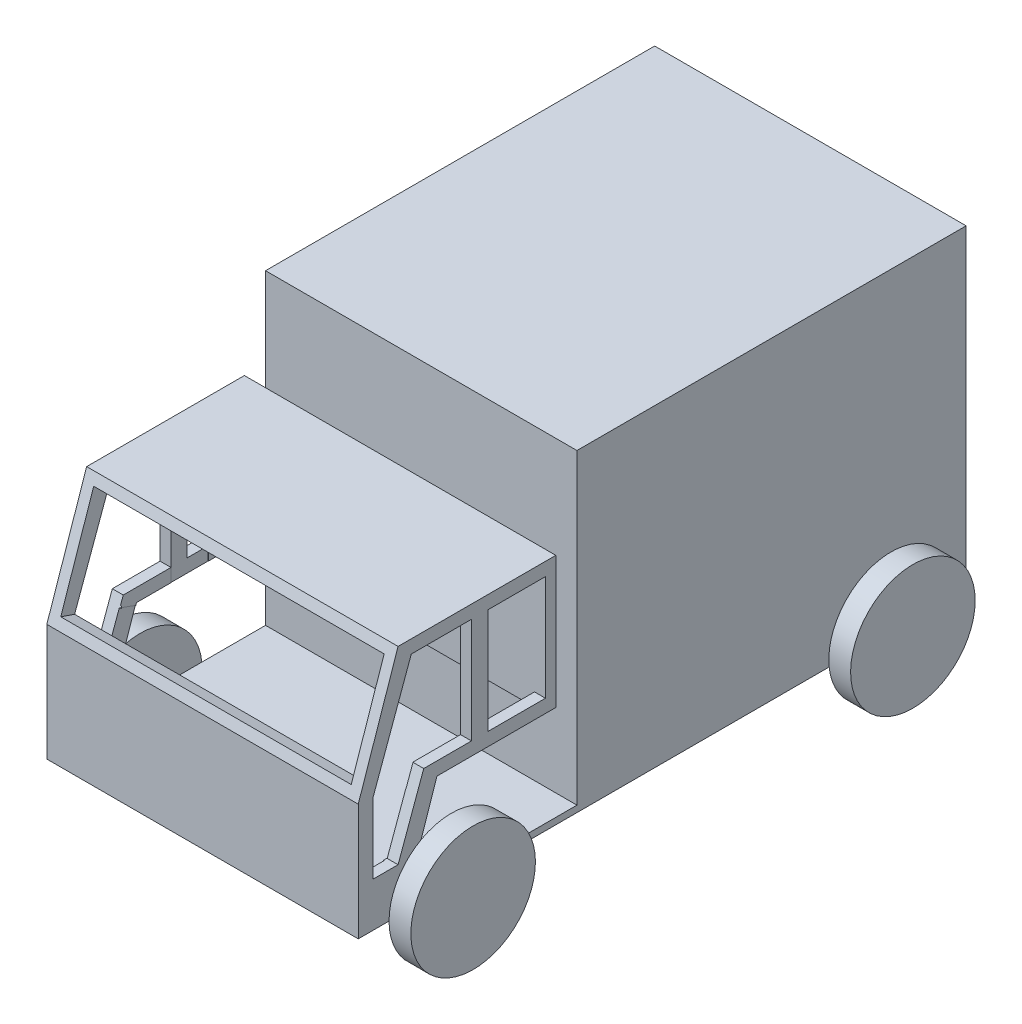
from build123d import *

# Parameters (mm, degrees)
IZIM2_W                     = 624.83438286
IZIM2_H                     = 493.118424104
Y_KSEKLIK_EKSTR_ZYON1_DEPTH = 500
IZIM4_R                     = 100
Y_KSEKLIK_EKSTR_ZYON2_DEPTH = 35
IZIM5_W                     = 975.967830922
IZIM5_H                     = 10.395315862
Y_KSEKLIK_EKSTR_ZYON3_DEPTH = 500
IZIM6_W                     = 317.202351564
IZIM6_H                     = 374.704466417
Y_KSEKLIK_EKSTR_ZYON4_DEPTH = 500
KES_EKSTR_ZYON1_DEPTH       = 500
KES_EKSTR_ZYON2_DEPTH       = 500
KES_EKSTR_ZYON3_DEPTH       = 500
IZIM11_R                    = 100
Y_KSEKLIK_EKSTR_ZYON5_DEPTH = 35
IZIM12_W                    = 466.303391348
IZIM12_H                    = 163.89871841
KES_EKSTR_ZYON4_DEPTH       = 35
IZIM17_W                    = 464.870730912
IZIM17_H                    = 199.827267797
KES_EKSTR_ZYON7_DEPTH       = 35
IZIM20_W                    = 465.660425645
IZIM20_H                    = 104.591429086
KES_EKSTR_ZYON8_DEPTH       = 35
IZIM21_W                    = 463.56331291
IZIM21_H                    = 33.15833205
KES_EKSTR_ZYON9_DEPTH       = 35
IZIM22_W                    = 465.770217683
IZIM22_H                    = 55.70279957
KES_EKSTR_ZYON10_DEPTH      = 35
IZIM23_W                    = 466.303391348
IZIM23_H                    = 30.655819637
KES_EKSTR_ZYON11_DEPTH      = 60
IZIM25_W                    = 26.274086754
IZIM25_H                    = 211.571078613
Y_KSEKLIK_EKSTR_ZYON6_DEPTH = 500
IZIM27_W                    = 465.215365456
IZIM27_H                    = 190.357875177
KES_EKSTR_ZYON12_DEPTH      = 60
IZIM28_R                    = 100
Y_KSEKLIK_EKSTR_ZYON7_DEPTH = 35


with BuildPart() as part:
    # Çizim2 → Yükseklik-Ekstrüzyon1 (new body)
    with BuildSketch(Plane(origin=(0, 0, 0), x_dir=(0, 0, -1), z_dir=(1, 0, 0))):
        with Locations((945.419542605, 684.894087956)):
            Rectangle(IZIM2_W, IZIM2_H)
    extrude(amount=-Y_KSEKLIK_EKSTR_ZYON1_DEPTH)

    # Çizim4 → Yükseklik-Ekstrüzyon2 (add)
    with BuildSketch(Plane(origin=(0, 0, 0), x_dir=(0, 0, -1), z_dir=(1, 0, 0))):
        with Locations((1137.354295612, 438.334875904)):
            Circle(IZIM4_R)
    extrude(amount=Y_KSEKLIK_EKSTR_ZYON2_DEPTH)

    # Çizim5 → Yükseklik-Ekstrüzyon3 (add)
    with BuildSketch(Plane(origin=(0, 0, 0), x_dir=(0, 0, -1), z_dir=(1, 0, 0))):
        with Locations((769.852818574, 433.137217973)):
            Rectangle(IZIM5_W, IZIM5_H)
    extrude(amount=-Y_KSEKLIK_EKSTR_ZYON3_DEPTH)

    # Çizim6 → Yükseklik-Ekstrüzyon4 (add)
    with BuildSketch(Plane(origin=(0, 0, 0), x_dir=(0, 0, -1), z_dir=(1, 0, 0))):
        with Locations((440.470078895, 615.291793251)):
            Rectangle(IZIM6_W, IZIM6_H)
    extrude(amount=-Y_KSEKLIK_EKSTR_ZYON4_DEPTH)

    # Çizim7 → Kes-Ekstrüzyon1 (cut)
    with BuildSketch(Plane(origin=(0, 0, 0), x_dir=(0, 0, -1), z_dir=(1, 0, 0))):
        Polygon((281.868903113, 802.644026459), (345.819234143, 802.644026459), (281.868903113, 615.29179325), align=None)
    extrude(amount=-KES_EKSTR_ZYON1_DEPTH, mode=Mode.SUBTRACT)

    # Çizim8 → Kes-Ekstrüzyon2 (cut)
    with BuildSketch(Plane(origin=(0, 0, 0), x_dir=(0, 0, -1), z_dir=(1, 0, 0))):
        Polygon((367.032437579, 781.430823023), (305.46881178, 612.286151281), (305.46881178, 499.123252309), (345.819234143, 499.123252309), (387.007160993, 612.286151281), (582.392266599, 612.286151281), (582.392266599, 781.430823023), align=None)
    extrude(amount=-KES_EKSTR_ZYON2_DEPTH, mode=Mode.SUBTRACT)

    # Çizim10 → Kes-Ekstrüzyon3 (cut)
    with BuildSketch(Plane(origin=(0, 0, 0), x_dir=(0, 0, -1), z_dir=(1, 0, 0))):
        Polygon((599.071254677, 438.334875904), (356.541223106, 438.334875904), (408.220364428, 591.072947846), (599.071254677, 591.072947846), align=None)
    extrude(amount=-KES_EKSTR_ZYON3_DEPTH, mode=Mode.SUBTRACT)

    # Çizim11 → Yükseklik-Ekstrüzyon5 (add)
    with BuildSketch(Plane(origin=(0, 0, 0), x_dir=(0, 0, -1), z_dir=(1, 0, 0))):
        with Locations((431.321316174, 427.939560042)):
            Circle(IZIM11_R)
    extrude(amount=Y_KSEKLIK_EKSTR_ZYON5_DEPTH)

    # Çizim12 → Kes-Ekstrüzyon4 (cut)
    with BuildSketch(Plane(origin=(0, -21.964844226, -64.349355999), x_dir=(1, 0, 0), z_dir=(0, 0.323037077, 0.94638631))):
        with Locations((-250, 772.34079435)):
            Rectangle(IZIM12_W, IZIM12_H)
    extrude(amount=-KES_EKSTR_ZYON4_DEPTH, mode=Mode.SUBTRACT)

    # Çizim17 → Kes-Ekstrüzyon7 (cut)
    with BuildSketch(Plane(origin=(0, 612.286151281, 0), x_dir=(1, 0, 0), z_dir=(0, 1, 0))):
        with Locations((-250, 482.478632701)):
            Rectangle(IZIM17_W, IZIM17_H)
    extrude(amount=-KES_EKSTR_ZYON7_DEPTH, mode=Mode.SUBTRACT)

    # Çizim20 → Kes-Ekstrüzyon8 (cut)
    with BuildSketch(Plane(origin=(0, -52.757830226, -144.950947246), x_dir=(1, 0, 0), z_dir=(0, 0.342020143, 0.939692621))):
        with Locations((-250.321482852, 639.324434245)):
            Rectangle(IZIM20_W, IZIM20_H)
    extrude(amount=-KES_EKSTR_ZYON8_DEPTH, mode=Mode.SUBTRACT)

    # Çizim21 → Kes-Ekstrüzyon9 (cut)
    with BuildSketch(Plane(origin=(0, -52.757830226, -144.950947246), x_dir=(1, 0, 0), z_dir=(0, 0.342020143, 0.939692621))):
        with Locations((-249.003107825, 691.169166414)):
            Rectangle(IZIM21_W, IZIM21_H)
    extrude(amount=-KES_EKSTR_ZYON9_DEPTH, mode=Mode.SUBTRACT)

    # Çizim22 → Kes-Ekstrüzyon10 (cut)
    with BuildSketch(Plane(origin=(0, -63.217651249, -186.84022059), x_dir=(-1, 0, 0), z_dir=(0, -0.320502572, -0.947247645))):
        with Locations((250.835570057, 555.815526561)):
            Rectangle(IZIM22_W, IZIM22_H)
    extrude(amount=-KES_EKSTR_ZYON10_DEPTH, mode=Mode.SUBTRACT)

    # Çizim23 → Kes-Ekstrüzyon11 (cut)
    with BuildSketch(Plane(origin=(0, 499.123252309, 0), x_dir=(1, 0, 0), z_dir=(0, 1, 0))):
        with Locations((-250, 324.988840267)):
            Rectangle(IZIM23_W, IZIM23_H)
    extrude(amount=-KES_EKSTR_ZYON11_DEPTH, mode=Mode.SUBTRACT)

    # Çizim25 → Yükseklik-Ekstrüzyon6 (add)
    with BuildSketch(Plane(origin=(0, 0, 0), x_dir=(0, 0, -1), z_dir=(1, 0, 0))):
        with Locations((476.795697093, 696.858487153)):
            Rectangle(IZIM25_W, IZIM25_H)
    extrude(amount=-Y_KSEKLIK_EKSTR_ZYON6_DEPTH)

    # Çizim27 → Kes-Ekstrüzyon12 (cut)
    with BuildSketch(Plane.XY.offset(-463.658653716)):
        with Locations((-250.172317272, 686.251885435)):
            Rectangle(IZIM27_W, IZIM27_H)
    extrude(amount=-KES_EKSTR_ZYON12_DEPTH, mode=Mode.SUBTRACT)

    # Çizim28 → Yükseklik-Ekstrüzyon7 (add)
    with BuildSketch(Plane.ZY.offset(500)):
        with Locations((-431.321316174, 427.939560042)):
            Circle(IZIM28_R)
        with Locations((-1135.713642363, 438.334875904)):
            Circle(IZIM28_R)
    extrude(amount=Y_KSEKLIK_EKSTR_ZYON7_DEPTH)


solid = part.part
